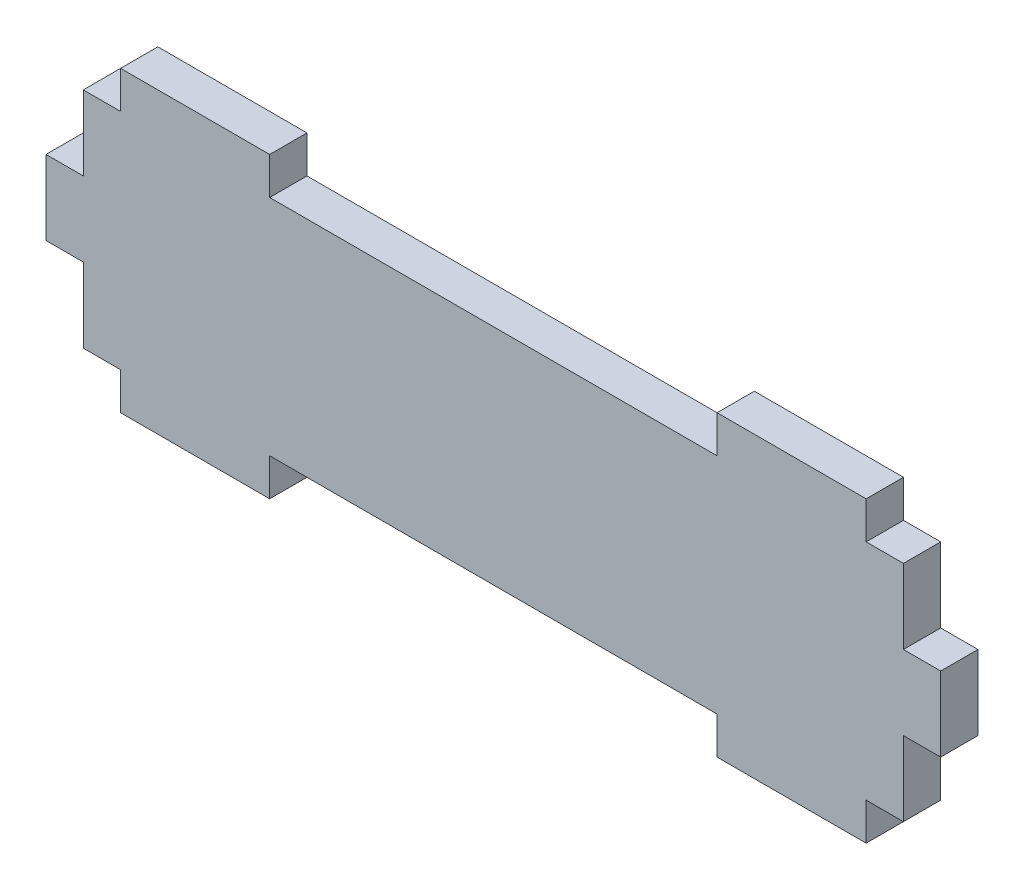
from build123d import *

# Parameters (mm, degrees)
BOSS_EXTRUDE1_DEPTH = 6.35


with BuildPart() as part:
    # Sketch1 → Boss-Extrude1 (new body)
    with BuildSketch(Plane.XY):
        Polygon((0, 19.05), (6.35, 19.05), (6.35, 6.35), (12.7, 6.35), (12.7, 0), (38.1, 0), (38.1, 6.35), (114.3, 6.35), (114.3, 0), (139.7, 0), (139.7, 6.35), (146.05, 6.35), (146.05, 19.05), (152.4, 19.05), (152.4, 31.75), (146.05, 31.75), (146.05, 44.45), (139.7, 44.45), (139.7, 50.8), (114.3, 50.8), (114.3, 44.45), (38.1, 44.45), (38.1, 50.8), (12.7, 50.8), (12.7, 44.45), (6.35, 44.45), (6.35, 31.75), (0, 31.75), align=None)
    extrude(amount=BOSS_EXTRUDE1_DEPTH)


solid = part.part
